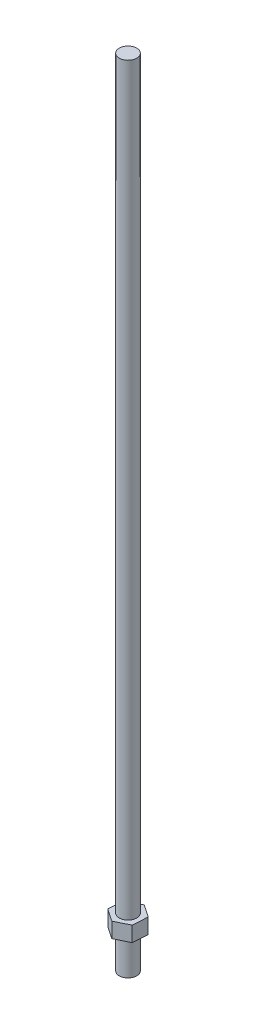
from build123d import *

# Parameters (mm, degrees)
SKETCH1_R           = 6.35
BOSS_EXTRUDE1_DEPTH = 577.85
BOSS_EXTRUDE2_START = 25.4
BOSS_EXTRUDE2_DEPTH = 11.049


with BuildPart() as part:
    # Sketch1 → Boss-Extrude1 (new body)
    with BuildSketch(Plane(origin=(0, 0, 0), x_dir=(1, 0, 0), z_dir=(0, 1, 0))):
        Circle(SKETCH1_R)
    extrude(amount=BOSS_EXTRUDE1_DEPTH)

    # Sketch3 → Boss-Extrude2 (add)
    with BuildSketch(Plane(origin=(0, 0, 0), x_dir=(1, 0, 0), z_dir=(0, 1, 0)).offset(BOSS_EXTRUDE2_START)):
        Polygon((9.876865428, 4.838907863), (0.747815578, 10.973070302), (-9.129049851, 6.134162439), (-9.876865428, -4.838907863), (-0.747815578, -10.973070302), (9.129049851, -6.134162439), align=None)
    extrude(amount=BOSS_EXTRUDE2_DEPTH)


solid = part.part
